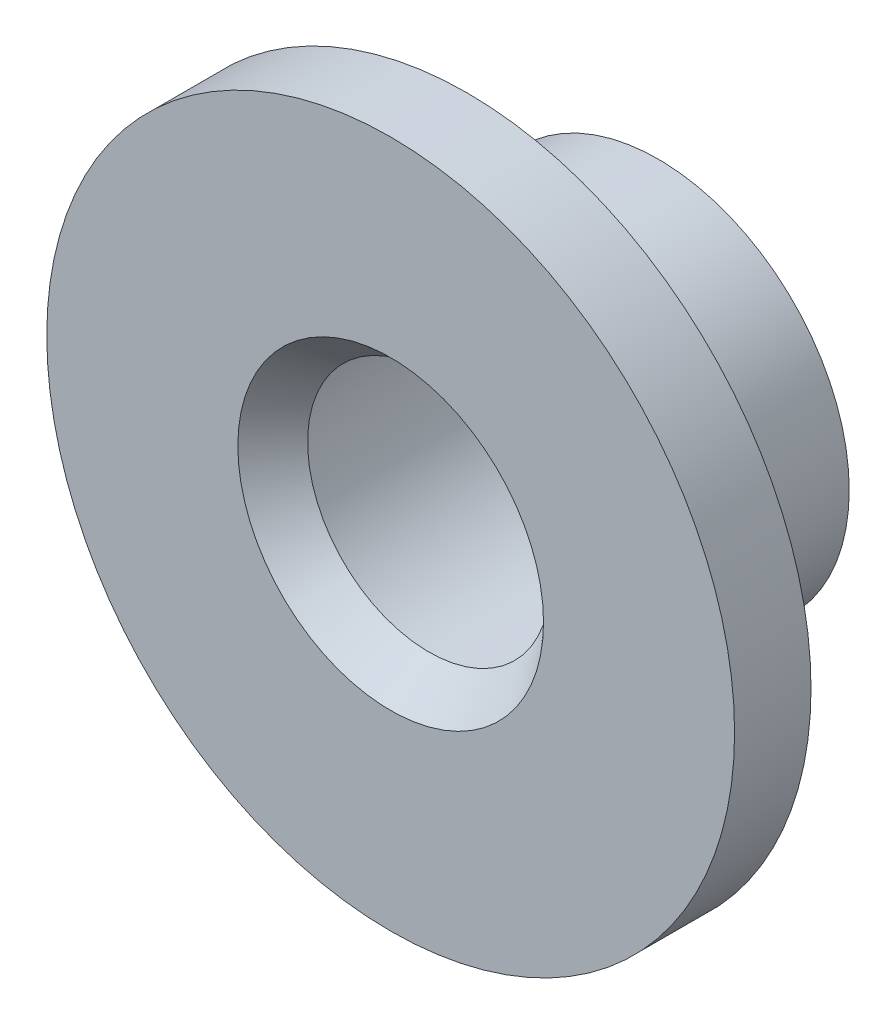
from build123d import *


with BuildPart() as part:
    # Sketch1 → Revolve1 (revolve)
    with BuildSketch(Plane(origin=(0, 0, 0), x_dir=(0, 0, -1), z_dir=(1, 0, 0)), mode=Mode.PRIVATE) as revolve1_sk:
        Polygon((0, 18), (0, 8), (2, 6.35), (2, 8), (14, 8), (14, 10), (4, 10), (4, 18), align=None)
    revolve(revolve1_sk.sketch.rotate(Axis((0, 0, 0), (0, 0, -1)), 90), axis=Axis((0, 0, 0), (0, 0, -1)))  # turned: the seam where the file's is


solid = part.part
